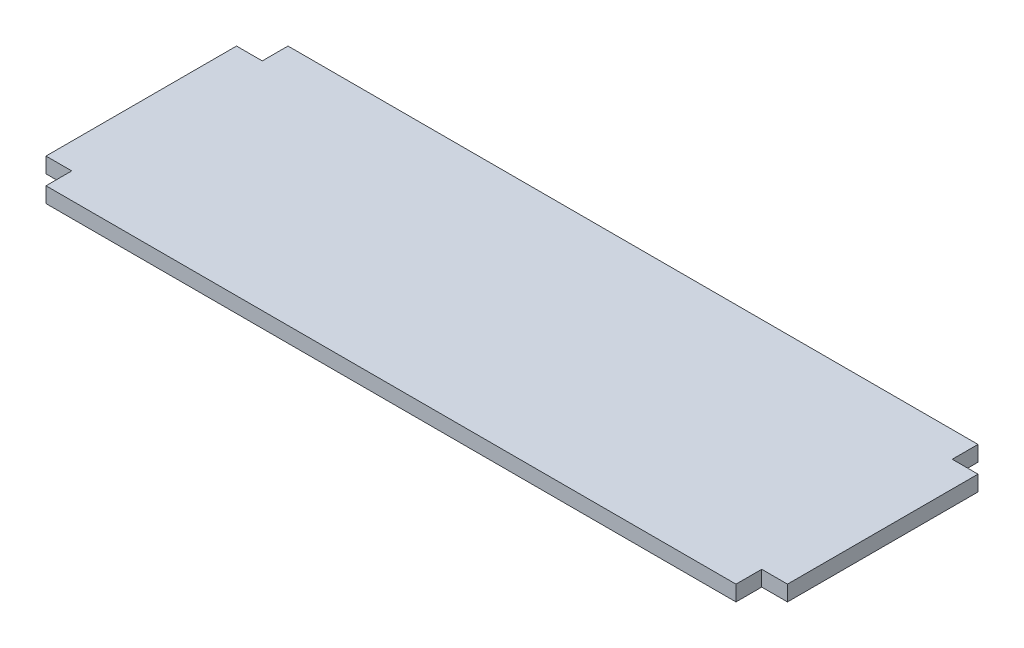
from build123d import *

# Parameters (mm, degrees)
BOSS_EXTRUDE1_DEPTH = 6


with BuildPart() as part:
    # Sketch1 → Boss-Extrude1 (new body)
    with BuildSketch(Plane(origin=(0, 0, 0), x_dir=(1, 0, 0), z_dir=(0, 1, 0))):
        Polygon((0, 84), (0, 10), (10, 10), (10, 0), (278, 0), (278, 10), (288, 10), (288, 84), (278, 84), (278, 94), (10, 94), (10, 84), align=None)
    extrude(amount=BOSS_EXTRUDE1_DEPTH)


solid = part.part
